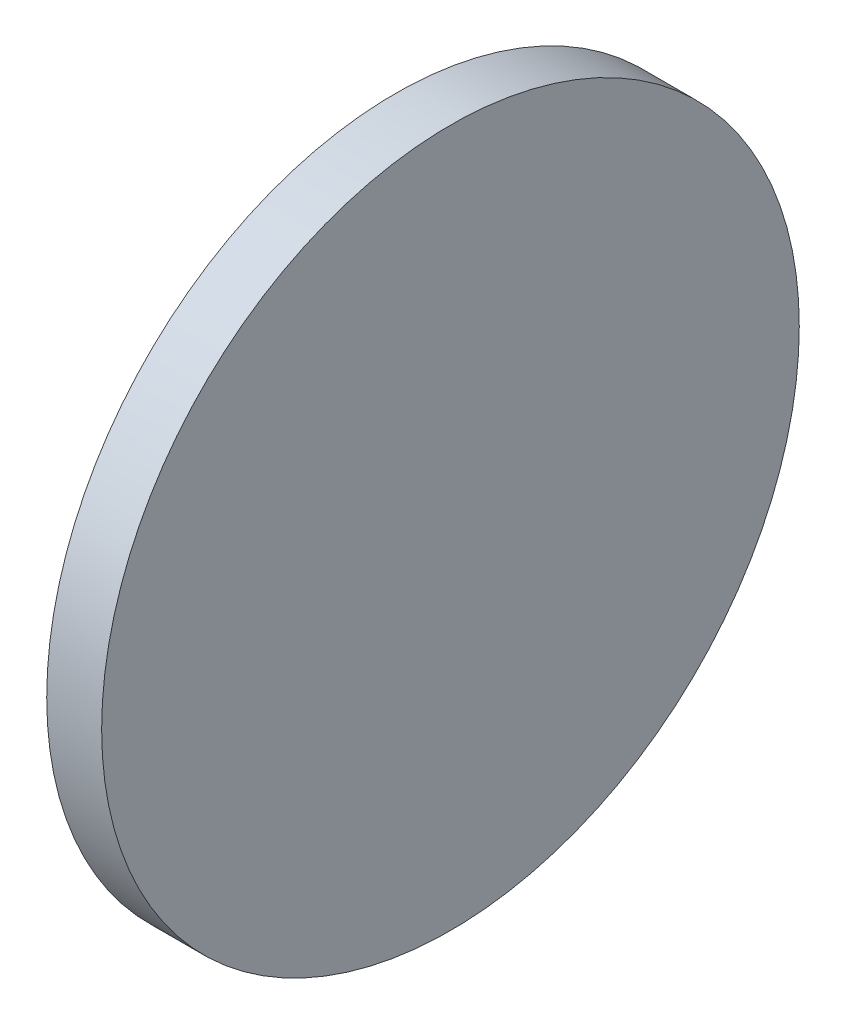
from build123d import *

# Parameters (mm, degrees)
SKETCH_1_W = 2
SKETCH_1_H = 12.7


with BuildPart() as part:
    # 草图1 → 旋转1 (revolve)
    with BuildSketch(Plane.XY, mode=Mode.PRIVATE) as revolve_1_sk:
        with Locations((174.877409758, 63.660146656)):
            Rectangle(SKETCH_1_W, SKETCH_1_H)
    revolve(revolve_1_sk.sketch.rotate(Axis((168.247513707, 57.310146656, 0), (1, 0, 0)), 90), axis=Axis((168.247513707, 57.310146656, 0), (1, 0, 0)))  # turned: the seam where the file's is


solid = part.part
